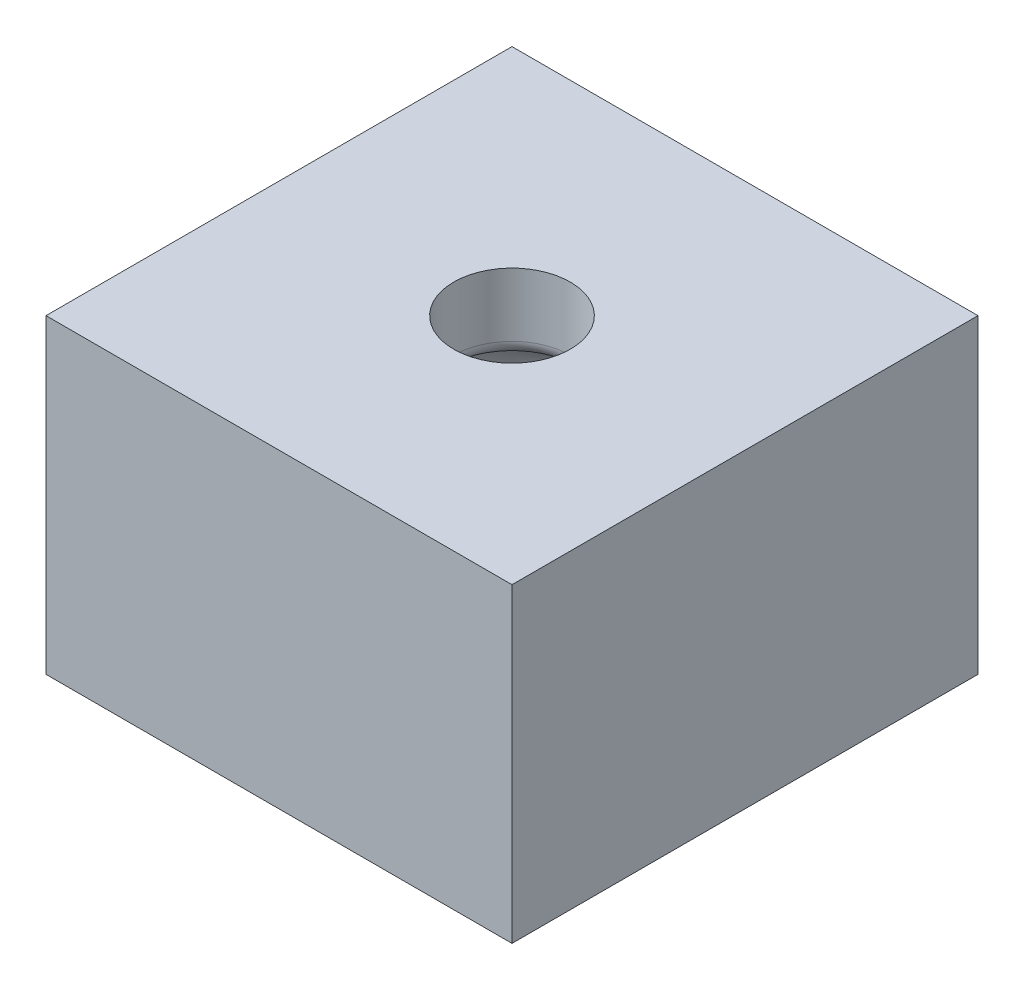
from build123d import *

# Parameters (mm, degrees)
SKETCH1_W           = 152.4
SKETCH1_H           = 152.4
BOSS_EXTRUDE1_DEPTH = 101.6


with BuildPart() as part:
    # Sketch1 → Boss-Extrude1 (new body)
    with BuildSketch(Plane(origin=(0, 0, 0), x_dir=(1, 0, 0), z_dir=(0, 1, 0))):
        Rectangle(SKETCH1_W, SKETCH1_H)
    extrude(amount=BOSS_EXTRUDE1_DEPTH)

    # Sketch3 → Cut-Revolve4 (revolve, cut)
    with BuildSketch(Plane.XY):
        with BuildLine():
            Line((-19.05, 80.853685298), (-19.05, 101.6))
            Line((-19.05, 101.6), (0, 101.6))
            Line((0, 101.6), (0, 25.4))
            Line((0, 25.4), (-19.05, 25.4))
            ThreePointArc((-19.05, 25.4), (-44.361028612, 48.675892989), (-23.283333333, 75.844737748))
            ThreePointArc((-23.283333333, 75.844737748), (-20.250085912, 77.574559398), (-19.05, 80.853685298))
        make_face()
    revolve(axis=Axis((0, 101.6, 0), (0, -1, 0)), mode=Mode.SUBTRACT)


solid = part.part
